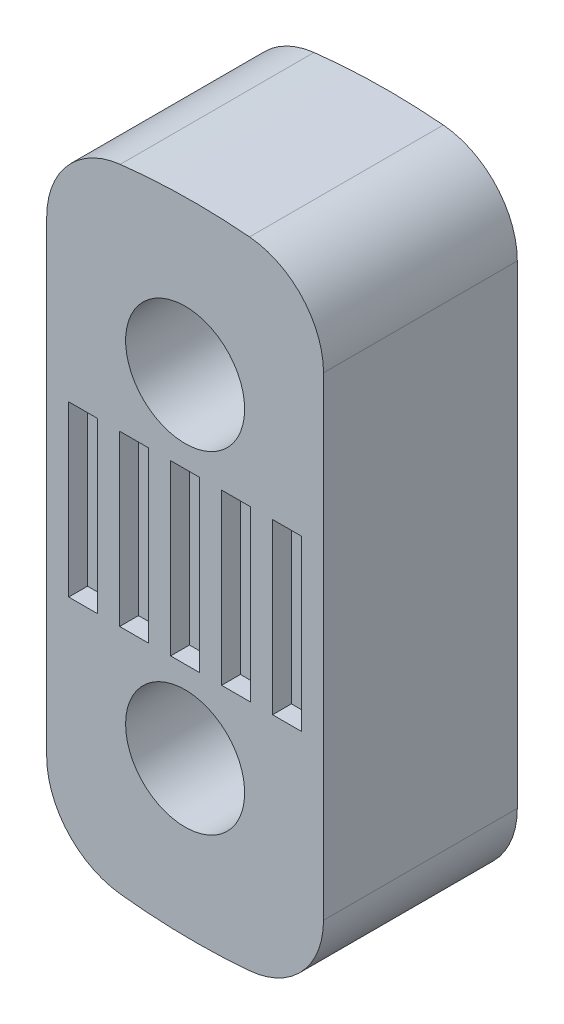
from build123d import *

# Parameters (mm, degrees)
SKETCH1_R           = 2.15
BOSS_EXTRUDE1_DEPTH = 7
SKETCH4_W           = 1.04528
SKETCH4_H           = 6.1088
CUT_EXTRUDE2_DEPTH  = 0.68


with BuildPart() as part:
    # Sketch1 → Boss-Extrude1 (new body)
    with BuildSketch(Plane.XY):
        with BuildLine():
            Line((-5, 14.434422223), (-5, -2.434422223))
            ThreePointArc((-5, -2.434422223), (-4.239496508, -4.429977284), (-2.343767283, -5.413245441))
            ThreePointArc((-2.343767283, -5.413245441), (-1.151217334, -5.519255542), (0.045204926, -5.563834645))
            ThreePointArc((0.045204926, -5.563834645), (1.187062084, -5.549004877), (2.326819369, -5.478216303))
            ThreePointArc((2.326819369, -5.478216303), (4.230533554, -4.540680035), (5, -2.563049296))
            Line((5, -2.563049296), (5, 14.563049296))
            ThreePointArc((5, 14.563049296), (4.230533554, 16.540680035), (2.326819369, 17.478216303))
            ThreePointArc((2.326819369, 17.478216303), (1.187062084, 17.549004877), (0.045204926, 17.563834645))
            ThreePointArc((0.045204926, 17.563834645), (-1.151217334, 17.519255542), (-2.343767283, 17.413245441))
            ThreePointArc((-2.343767283, 17.413245441), (-4.239496508, 16.429977284), (-5, 14.434422223))
        make_face()
        Circle(SKETCH1_R, mode=Mode.SUBTRACT)
        with Locations((0, 12)):
            Circle(SKETCH1_R, mode=Mode.SUBTRACT)
    extrude(amount=BOSS_EXTRUDE1_DEPTH)

    # Sketch4 → Cut-Extrude2 (cut)
    with BuildSketch(Plane.XY.offset(7)):
        with Locations((-3.68176, 6)):
            Rectangle(SKETCH4_W, SKETCH4_H)
        with Locations((-1.84088, 6)):
            Rectangle(SKETCH4_W, SKETCH4_H)
        with Locations((0, 6)):
            Rectangle(SKETCH4_W, SKETCH4_H)
        with Locations((1.84088, 6)):
            Rectangle(SKETCH4_W, SKETCH4_H)
        with Locations((3.68176, 6)):
            Rectangle(SKETCH4_W, SKETCH4_H)
    extrude(amount=-CUT_EXTRUDE2_DEPTH, mode=Mode.SUBTRACT)


solid = part.part
